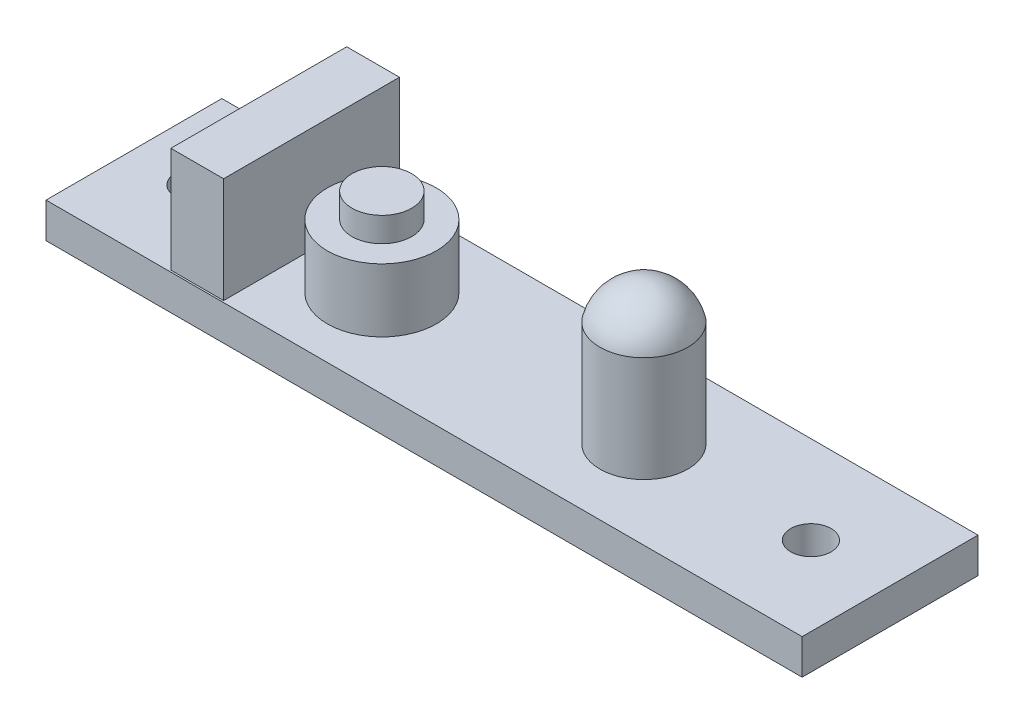
from build123d import *

# Parameters (mm, degrees)
SKETCH1_W               = 43
SKETCH1_H               = 10
BOSS_EXTRUDE1_DEPTH     = 2
SKETCH2_W               = 3
SKETCH2_H               = 10
BOSS_EXTRUDE2_DEPTH     = 6
SKETCH4_R               = 3.1
BOSS_EXTRUDE3_DEPTH     = 3.6
SKETCH6_R               = 1.7
BOSS_EXTRUDE5_DEPTH     = 1.4
SKETCH7_R               = 2.5
BOSS_EXTRUDE6_DEPTH     = 6
DOME1_FACE_RADIUS       = 2.5
DOME1_HEIGHT            = 2
SKETCH8_R               = 1.15
CUT_EXTRUDE1_DEPTH      = 9
CUT_EXTRUDE1_DEPTH_BACK = 3


with BuildPart() as part:
    # Sketch1 → Boss-Extrude1 (new body)
    with BuildSketch(Plane(origin=(0, 0, 0), x_dir=(1, 0, 0), z_dir=(0, 1, 0))):
        Rectangle(SKETCH1_W, SKETCH1_H)
    extrude(amount=BOSS_EXTRUDE1_DEPTH)

    # Sketch2 → Boss-Extrude2 (add)
    with BuildSketch(Plane(origin=(0, 2, 0), x_dir=(1, 0, 0), z_dir=(0, 1, 0))):
        with Locations((-13, 0.1)):
            Rectangle(SKETCH2_W, SKETCH2_H)
    extrude(amount=BOSS_EXTRUDE2_DEPTH)

    # Sketch4 → Boss-Extrude3 (add)
    with BuildSketch(Plane(origin=(0, 2, 0), x_dir=(1, 0, 0), z_dir=(0, 1, 0))):
        with Locations((-7.4, 0)):
            Circle(SKETCH4_R)
    extrude(amount=BOSS_EXTRUDE3_DEPTH)

    # Sketch6 → Boss-Extrude5 (add)
    with BuildSketch(Plane(origin=(0, 5.6, 0), x_dir=(1, 0, 0), z_dir=(0, 1, 0))):
        with Locations((-7.4, 0)):
            Circle(SKETCH6_R)
    extrude(amount=BOSS_EXTRUDE5_DEPTH)

    # Sketch7 → Boss-Extrude6 (add)
    with BuildSketch(Plane(origin=(0, 2, 0), x_dir=(1, 0, 0), z_dir=(0, 1, 0))):
        with Locations((7.5, 0)):
            Circle(SKETCH7_R)
    extrude(amount=BOSS_EXTRUDE6_DEPTH)

    # Dome1: a dome of height H over a round flat face of radius A is a cap of a sphere of radius (A * A + H * H) / (2 * H)
    dome1_r = (DOME1_FACE_RADIUS * DOME1_FACE_RADIUS + DOME1_HEIGHT * DOME1_HEIGHT) / (2 * DOME1_HEIGHT)
    dome1_base = Plane((7.5, 8, 0), z_dir=(0, 1, 0))
    with Locations(dome1_base.offset(DOME1_HEIGHT - dome1_r)):
        dome1_ball = Sphere(dome1_r, mode=Mode.PRIVATE)
    add(split(dome1_ball, bisect_by=dome1_base, keep=Keep.TOP, mode=Mode.PRIVATE))

    # Sketch8 → Cut-Extrude1 (cut, two sides)
    with BuildSketch(Plane(origin=(0, 2, 0), x_dir=(1, 0, 0), z_dir=(0, 1, 0))) as cut_extrude1_sk:
        with Locations((-18, 0)):
            Circle(SKETCH8_R)
        with Locations((17, 0)):
            Circle(SKETCH8_R)
    extrude(amount=CUT_EXTRUDE1_DEPTH, mode=Mode.SUBTRACT)
    extrude(cut_extrude1_sk.sketch, amount=-CUT_EXTRUDE1_DEPTH_BACK, mode=Mode.SUBTRACT)


solid = part.part
